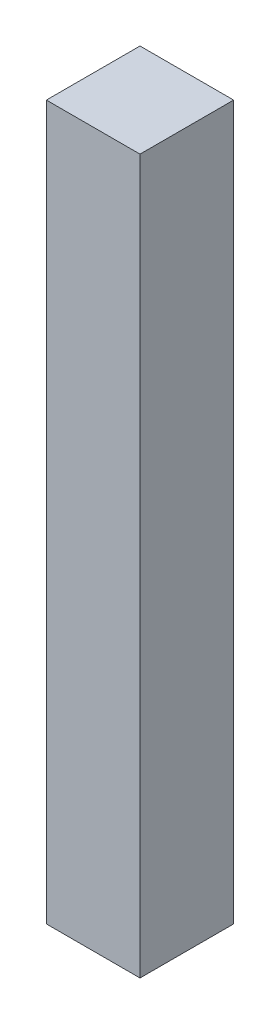
from build123d import *

# Parameters (mm, degrees)
SKETCH1_W           = 40
SKETCH1_H           = 40
BOSS_EXTRUDE1_DEPTH = 304.8


with BuildPart() as part:
    # Sketch1 → Boss-Extrude1 (new body)
    with BuildSketch(Plane(origin=(0, 0, 0), x_dir=(1, 0, 0), z_dir=(0, 1, 0))):
        Rectangle(SKETCH1_W, SKETCH1_H)
    extrude(amount=BOSS_EXTRUDE1_DEPTH)


solid = part.part
